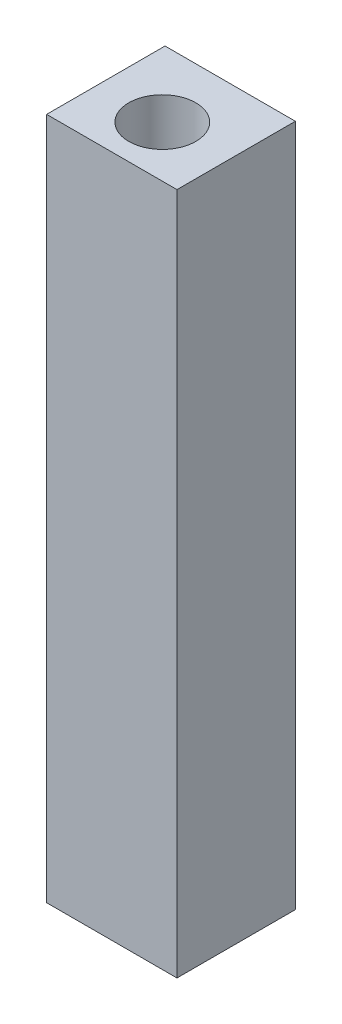
from build123d import *

# Parameters (mm, degrees)
SKETCH1_W           = 19.088511203
SKETCH1_H           = 17.340971445
BOSS_EXTRUDE1_DEPTH = 100
SKETCH2_R           = 4.909616735
CUT_EXTRUDE1_DEPTH  = 10


with BuildPart() as part:
    # Sketch1 → Boss-Extrude1 (new body)
    with BuildSketch(Plane(origin=(0, 0, 0), x_dir=(1, 0, 0), z_dir=(0, 1, 0))):
        with Locations((-15.862283958, 8.670485723)):
            Rectangle(SKETCH1_W, SKETCH1_H)
    extrude(amount=BOSS_EXTRUDE1_DEPTH)

    # Sketch2 → Cut-Extrude1 (cut)
    with BuildSketch(Plane(origin=(0, 100, 0), x_dir=(1, 0, 0), z_dir=(0, 1, 0))):
        with Locations((-15.953953264, 7.486287958)):
            Circle(SKETCH2_R)
    extrude(amount=-CUT_EXTRUDE1_DEPTH, mode=Mode.SUBTRACT)


solid = part.part
